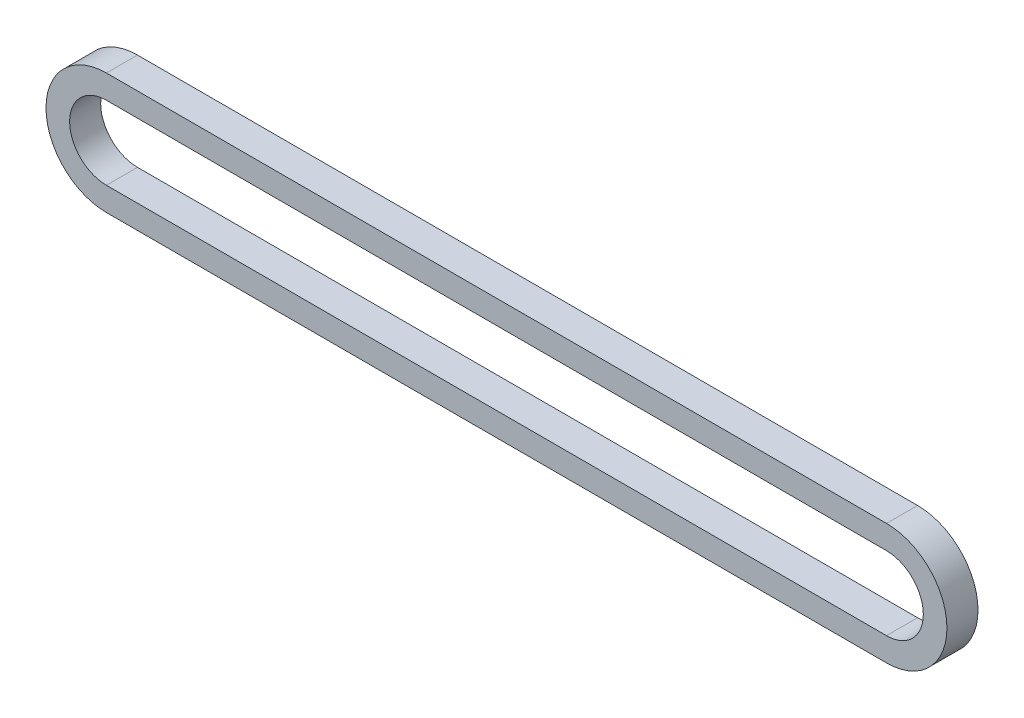
from build123d import *

# Parameters (mm, degrees)
EXTRUDE_THIN1_DEPTH = 5.8801


with BuildPart() as part:
    # Sketch1 → Extrude-Thin1 (new body, symmetric)
    with BuildSketch(Plane.XY):
        with BuildLine():
            Line((295.275, -22.871286991), (0, -22.871286991))
            ThreePointArc((0, -22.871286991), (-22.871286991, 0), (0, 22.871286991))
            Line((0, 22.871286991), (295.275, 22.871286991))
            ThreePointArc((295.275, 22.871286991), (318.146286991, 0), (295.275, -22.871286991))
        make_face()
        with BuildLine():
            Line((295.275, -13.930486991), (0, -13.930486991))
            ThreePointArc((0, -13.930486991), (-13.930486991, 0), (0, 13.930486991))
            Line((0, 13.930486991), (295.275, 13.930486991))
            ThreePointArc((295.275, 13.930486991), (309.205486991, 0), (295.275, -13.930486991))
        make_face(mode=Mode.SUBTRACT)
    extrude(amount=EXTRUDE_THIN1_DEPTH, both=True)


solid = part.part
